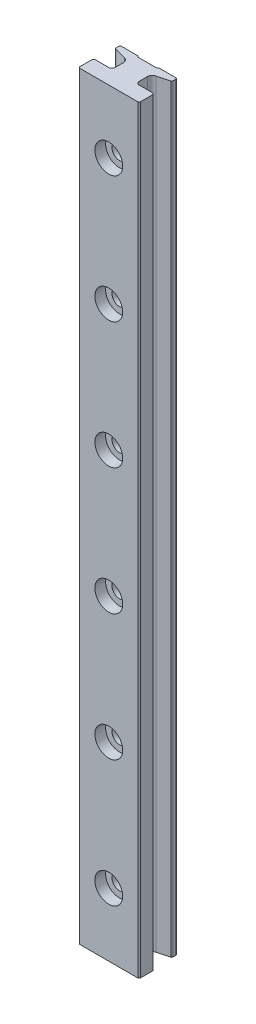
from build123d import *

# Parameters (mm, degrees)
SKETCH1_W           = 9
SKETCH1_H           = 120
BOSS_EXTRUDE1_DEPTH = 6.3
CUT_EXTRUDE1_DEPTH  = 121
SKETCH3_W           = 2.4
SKETCH3_H           = 120
BOSS_EXTRUDE2_DEPTH = 2.9
CUT_EXTRUDE2_DEPTH  = 121
SKETCH5_W           = 2.4
SKETCH5_H           = 120
BOSS_EXTRUDE3_DEPTH = 2.9
CUT_EXTRUDE3_DEPTH  = 121
HOLE1_D             = 2.4
HOLE1_DEPTH         = 6.3
HOLE1_CBORE_D       = 4.4
HOLE1_CBORE_DEPTH   = 1.7
HOLE2_D             = 2.4
HOLE2_DEPTH         = 6.3
HOLE2_CBORE_D       = 4.4
HOLE2_CBORE_DEPTH   = 1.7
HOLE3_D             = 2.4
HOLE3_DEPTH         = 6.3
HOLE3_CBORE_D       = 4.4
HOLE3_CBORE_DEPTH   = 1.7
HOLE4_D             = 2.4
HOLE4_DEPTH         = 6.3
HOLE4_CBORE_D       = 4.4
HOLE4_CBORE_DEPTH   = 1.7
HOLE5_D             = 2.4
HOLE5_DEPTH         = 6.3
HOLE5_CBORE_D       = 4.4
HOLE5_CBORE_DEPTH   = 1.7
HOLE6_D             = 2.4
HOLE6_DEPTH         = 6.3
HOLE6_CBORE_D       = 4.4
HOLE6_CBORE_DEPTH   = 1.7
CHAMFER1_SIZE       = 0.2
CHAMFER2_SIZE       = 0.3
CHAMFER3_SIZE       = 0.2
CHAMFER4_SIZE       = 0.3
CHAMFER5_SIZE       = 0.2
CHAMFER6_SIZE       = 0.2
FILLET1_R           = 0.2
FILLET2_R           = 0.2
FILLET3_R           = 0.2
FILLET4_R           = 0.200000005
FILLET5_R           = 0.8
FILLET6_R           = 0.8


with BuildPart() as part:
    # Sketch1 → Boss-Extrude1 (new body)
    with BuildSketch(Plane.XY.offset(6.3)):
        Rectangle(SKETCH1_W, SKETCH1_H)
    extrude(amount=-BOSS_EXTRUDE1_DEPTH)

    # Sketch2 → Cut-Extrude1 (cut, through all)
    with BuildSketch(Plane(origin=(0, 60, 0), x_dir=(-1, 0, 0), z_dir=(0, 1, 0))):
        Polygon((4.5, 6.3), (1.9, 6.3), (1.9, 1.496667899), (4.5, 0.800000003), align=None)
    extrude(amount=-CUT_EXTRUDE1_DEPTH, mode=Mode.SUBTRACT)

    # Sketch3 → Boss-Extrude2 (add)
    with BuildSketch(Plane.ZY.offset(1.9)):
        with Locations((5.1, 0)):
            Rectangle(SKETCH3_W, SKETCH3_H)
    extrude(amount=BOSS_EXTRUDE2_DEPTH)

    # Sketch4 → Cut-Extrude2 (cut, through all)
    with BuildSketch(Plane(origin=(0, 60, 0), x_dir=(-1, 0, 0), z_dir=(0, 1, 0))):
        Polygon((-4.5, 0.800000003), (-1.9, 1.496667899), (-1.9, 6.3), (-4.5, 6.3), align=None)
    extrude(amount=-CUT_EXTRUDE2_DEPTH, mode=Mode.SUBTRACT)

    # Sketch5 → Boss-Extrude3 (add)
    with BuildSketch(Plane(origin=(1.9, 0, 0), x_dir=(0, 0, -1), z_dir=(1, 0, 0))):
        with Locations((-5.1, 0)):
            Rectangle(SKETCH5_W, SKETCH5_H)
    extrude(amount=BOSS_EXTRUDE3_DEPTH)

    # Sketch6 → Cut-Extrude3 (cut, through all)
    with BuildSketch(Plane.XZ.offset(60)):
        Polygon((-1.7, 0), (1.7, 0), (1.52, 0.18), (-1.52, 0.18), align=None)
    extrude(amount=-CUT_EXTRUDE3_DEPTH, mode=Mode.SUBTRACT)

    # Hole1
    with Locations(Plane.XY.offset(6.3)):
        with Locations((0, -50)):
            CounterBoreHole(HOLE1_D / 2, HOLE1_CBORE_D / 2, HOLE1_CBORE_DEPTH, depth=HOLE1_DEPTH)

    # Hole2
    with Locations(Plane.XY.offset(6.3)):
        with Locations((0, -30)):
            CounterBoreHole(HOLE2_D / 2, HOLE2_CBORE_D / 2, HOLE2_CBORE_DEPTH, depth=HOLE2_DEPTH)

    # Hole3
    with Locations(Plane.XY.offset(6.3)):
        with Locations((0, -10)):
            CounterBoreHole(HOLE3_D / 2, HOLE3_CBORE_D / 2, HOLE3_CBORE_DEPTH, depth=HOLE3_DEPTH)

    # Hole4
    with Locations(Plane.XY.offset(6.3)):
        with Locations((0, 10)):
            CounterBoreHole(HOLE4_D / 2, HOLE4_CBORE_D / 2, HOLE4_CBORE_DEPTH, depth=HOLE4_DEPTH)

    # Hole5
    with Locations(Plane.XY.offset(6.3)):
        with Locations((0, 30)):
            CounterBoreHole(HOLE5_D / 2, HOLE5_CBORE_D / 2, HOLE5_CBORE_DEPTH, depth=HOLE5_DEPTH)

    # Hole6
    with Locations(Plane.XY.offset(6.3)):
        with Locations((0, 50)):
            CounterBoreHole(HOLE6_D / 2, HOLE6_CBORE_D / 2, HOLE6_CBORE_DEPTH, depth=HOLE6_DEPTH)

    # Chamfer1
    chamfer1_edges = [part.edges().sort_by_distance(p)[0] for p in [
        (4.8, 0, 6.3),
    ]]
    chamfer(chamfer1_edges, length=CHAMFER1_SIZE)

    # Chamfer2
    chamfer2_edges = [part.edges().sort_by_distance(p)[0] for p in [
        (1.9, 0, 3.9),
    ]]
    chamfer(chamfer2_edges, length=CHAMFER2_SIZE)

    # Chamfer3
    chamfer3_edges = [part.edges().sort_by_distance(p)[0] for p in [
        (-4.8, 0, 6.3),
    ]]
    chamfer(chamfer3_edges, length=CHAMFER3_SIZE)

    # Chamfer4
    chamfer4_edges = [part.edges().sort_by_distance(p)[0] for p in [
        (-1.9, 0, 3.9),
    ]]
    chamfer(chamfer4_edges, length=CHAMFER4_SIZE)

    # Chamfer5
    chamfer5_edges = [part.edges().sort_by_distance(p)[0] for p in [
        (-4.8, 0, 3.9),
    ]]
    chamfer(chamfer5_edges, length=CHAMFER5_SIZE)

    # Chamfer6
    chamfer6_edges = [part.edges().sort_by_distance(p)[0] for p in [
        (4.8, 0, 3.9),
    ]]
    chamfer(chamfer6_edges, length=CHAMFER6_SIZE)

    # Fillet1
    fillet1_edges = [part.edges().sort_by_distance(p)[0] for p in [
        (-4.5, 0, 0),
    ]]
    fillet(fillet1_edges, radius=FILLET1_R)

    # Fillet2
    fillet2_edges = [part.edges().sort_by_distance(p)[0] for p in [
        (-4.5, 0, 0.800000003),
    ]]
    fillet(fillet2_edges, radius=FILLET2_R)

    # Fillet3
    fillet3_edges = [part.edges().sort_by_distance(p)[0] for p in [
        (4.5, 0, 0),
    ]]
    fillet(fillet3_edges, radius=FILLET3_R)

    # Fillet4
    fillet4_edges = [part.edges().sort_by_distance(p)[0] for p in [
        (4.5, 0, 0.800000003),
    ]]
    fillet(fillet4_edges, radius=FILLET4_R)

    # Fillet5
    fillet5_edges = [part.edges().sort_by_distance(p)[0] for p in [
        (-1.9, 0, 1.496667899),
    ]]
    fillet(fillet5_edges, radius=FILLET5_R)

    # Fillet6
    fillet6_edges = [part.edges().sort_by_distance(p)[0] for p in [
        (1.9, 0, 1.496667899),
    ]]
    fillet(fillet6_edges, radius=FILLET6_R)


solid = part.part
